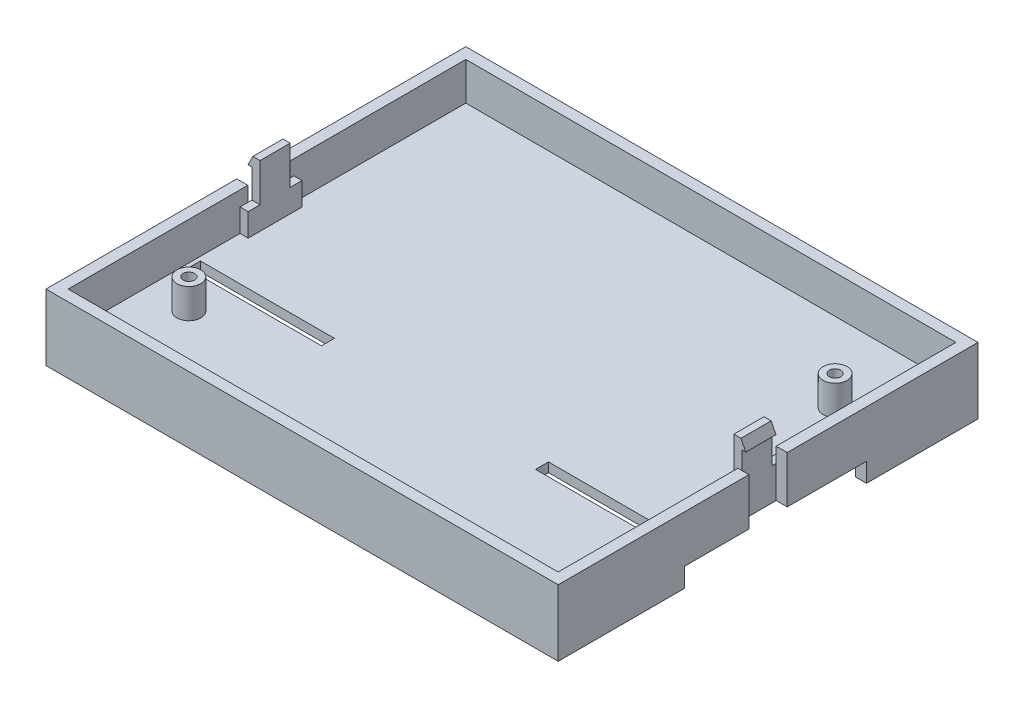
from build123d import *

# Parameters (mm, degrees)
CROQUIS1_W                          = 103.98
CROQUIS1_H                          = 2.475
SALIENTE_EXTRUIR1_DEPTH             = 2
SALIENTE_EXTRUIR2_DEPTH             = 6.3
CROQUIS3_W                          = 103.98
CROQUIS3_H                          = 8.775
SALIENTE_EXTRUIR3_DEPTH             = 12.75
CORTAR_EXTRUIR1_DEPTH               = 0.8
CORTAR_EXTRUIR2_DEPTH               = 0.8
CROQUIS6_W                          = 8.775
CROQUIS6_H                          = 12.8
CORTAR_EXTRUIR3_DEPTH               = 98.98
CROQUIS7_W                          = 1.7
CROQUIS7_H                          = 2.475
CORTAR_EXTRUIR4_DEPTH               = 2
CROQUIS8_W                          = 1.7
CROQUIS8_H                          = 2.475
CORTAR_EXTRUIR5_DEPTH               = 6
CROQUIS9_W                          = 1.7
CROQUIS9_H                          = 2.475
CORTAR_EXTRUIR6_DEPTH               = 6
SALIENTE_EXTRUIR4_DEPTH             = 2.475
CROQUIS11_W                         = 102.38
CROQUIS11_H                         = 1.95
SALIENTE_EXTRUIR5_DEPTH             = 38.225
CROQUIS12_W                         = 102.38
CROQUIS12_H                         = 2.31
SALIENTE_EXTRUIR6_DEPTH             = 7.9
CROQUIS13_W                         = 102.38
CROQUIS13_H                         = 1.95
SALIENTE_EXTRUIR7_DEPTH             = 38.225
CROQUIS14_W                         = 39.85
CROQUIS14_H                         = 9.85
SALIENTE_EXTRUIR8_DEPTH             = 2.31
CROQUIS15_W                         = 39.85
CROQUIS15_H                         = 9.85
SALIENTE_EXTRUIR9_DEPTH             = 2.31
CROQUIS16_W                         = 28
CROQUIS16_H                         = 2.7
CORTAR_EXTRUIR7_DEPTH               = 2.95
CROQUIS17_W                         = 28
CROQUIS17_H                         = 2.7
CORTAR_EXTRUIR8_DEPTH               = 2.95
CROQUIS18_W                         = 107
CROQUIS18_H                         = 26.41
SALIENTE_EXTRUIR10_DEPTH            = 4
CROQUIS19_W                         = 102.38
CROQUIS19_H                         = 2.31
SALIENTE_EXTRUIR11_DEPTH            = 7.9
CROQUIS20_W                         = 39.85
CROQUIS20_H                         = 9.85
SALIENTE_EXTRUIR12_DEPTH            = 2.31
CROQUIS21_W                         = 39.85
CROQUIS21_H                         = 9.85
SALIENTE_EXTRUIR13_DEPTH            = 2.31
SALIENTE_EXTRUIR14_DEPTH            = 4
SALIENTE_EXTRUIR15_DEPTH            = 4
CROQUIS24_W                         = 47
CROQUIS24_H                         = 4
CORTAR_EXTRUIR9_DEPTH               = 24.1
CORTAR_EXTRUIR10_REACH              = 106.69
CROQUIS25_W                         = 22.3
CROQUIS25_H                         = 4
CORTAR_EXTRUIR11_REACH              = 106.69
CROQUIS26_W                         = 4
CROQUIS26_H                         = 22.3
SALIENTE_EXTRUIR16_DEPTH            = 25.9
SALIENTE_EXTRUIR17_DEPTH            = 25.9
CROQUIS29_W                         = 2.5
CROQUIS29_H                         = 6.2
CROQUIS30_W                         = 2.5
CROQUIS30_H                         = 6.2
DI_METRO_DE_TALADRO_2_4_2_4_1_D     = 2.4
DI_METRO_DE_TALADRO_2_4_2_4_1_DEPTH = 6.2


with BuildPart() as part:
    # Croquis1 → Saliente-Extruir1 (new body)
    with BuildSketch(Plane(origin=(0, 18.75, 0), x_dir=(1, 0, 0), z_dir=(0, 1, 0))):
        with Locations((0, 4.3875)):
            Rectangle(CROQUIS1_W, CROQUIS1_H)
    extrude(amount=-SALIENTE_EXTRUIR1_DEPTH)

    # Croquis2 → Saliente-Extruir2 (add)
    with BuildSketch(Plane.XY.offset(-3.15)):
        Polygon((-51.99, 16.75), (-50.99, 18.75), (50.99, 18.75), (51.99, 16.75), align=None)
    extrude(amount=SALIENTE_EXTRUIR2_DEPTH)

    # Croquis3 → Saliente-Extruir3 (add)
    with BuildSketch(Plane.XZ.offset(-16.75)):
        with Locations((0, -1.2375)):
            Rectangle(CROQUIS3_W, CROQUIS3_H)
    extrude(amount=SALIENTE_EXTRUIR3_DEPTH)

    # Croquis4 → Cortar-Extruir1 (cut)
    with BuildSketch(Plane(origin=(51.99, 0, 0), x_dir=(0, 0, -1), z_dir=(1, 0, 0))):
        Polygon((5.625, 4), (5.625, 18.75), (3.15, 18.75), (3.15, 18.35), (3.15, 16.75), (-3.15, 16.75), (-3.15, 4), align=None)
    extrude(amount=-CORTAR_EXTRUIR1_DEPTH, mode=Mode.SUBTRACT)

    # Croquis5 → Cortar-Extruir2 (cut)
    with BuildSketch(Plane.ZY.offset(51.99)):
        Polygon((-5.625, 4), (3.15, 4), (3.15, 16.75), (-3.15, 16.75), (-3.15, 18.35), (-3.15, 18.75), (-5.625, 18.75), align=None)
    extrude(amount=-CORTAR_EXTRUIR2_DEPTH, mode=Mode.SUBTRACT)

    # Croquis6 → Cortar-Extruir3 (cut)
    with BuildSketch(Plane(origin=(49.49, 0, 0), x_dir=(0, 0, -1), z_dir=(1, 0, 0))):
        with Locations((1.2375, 12.35)):
            Rectangle(CROQUIS6_W, CROQUIS6_H)
    extrude(amount=-CORTAR_EXTRUIR3_DEPTH, mode=Mode.SUBTRACT)

    # Croquis7 → Cortar-Extruir4 (cut)
    with BuildSketch(Plane(origin=(0, 18.75, 0), x_dir=(-1, 0, 0), z_dir=(0, 1, 0))):
        with Locations((50.34, -4.3875)):
            Rectangle(CROQUIS7_W, CROQUIS7_H)
        with Locations((-50.34, -4.3875)):
            Rectangle(CROQUIS7_W, CROQUIS7_H)
    extrude(amount=-CORTAR_EXTRUIR4_DEPTH, mode=Mode.SUBTRACT)

    # Croquis8 → Cortar-Extruir5 (cut)
    with BuildSketch(Plane(origin=(0, 16.75, 0), x_dir=(-1, 0, 0), z_dir=(0, 1, 0))):
        with Locations((-50.34, -4.3875)):
            Rectangle(CROQUIS8_W, CROQUIS8_H)
    extrude(amount=-CORTAR_EXTRUIR5_DEPTH, mode=Mode.SUBTRACT)

    # Croquis9 → Cortar-Extruir6 (cut)
    with BuildSketch(Plane(origin=(0, 16.75, 0), x_dir=(-1, 0, 0), z_dir=(0, 1, 0))):
        with Locations((50.34, -4.3875)):
            Rectangle(CROQUIS9_W, CROQUIS9_H)
    extrude(amount=-CORTAR_EXTRUIR6_DEPTH, mode=Mode.SUBTRACT)

    # Croquis10 → Saliente-Extruir4 (add)
    with BuildSketch(Plane.XY.offset(3.15)):
        Polygon((49.49, 5.95), (49.49, 10.75), (51.19, 10.75), (51.19, 4), (-51.19, 4), (-51.19, 10.75), (-49.49, 10.75), (-49.49, 5.95), align=None)
    extrude(amount=SALIENTE_EXTRUIR4_DEPTH)

    # Croquis11 → Saliente-Extruir5 (add)
    with BuildSketch(Plane.XY.offset(5.625)):
        with Locations((0, 4.975)):
            Rectangle(CROQUIS11_W, CROQUIS11_H)
    extrude(amount=SALIENTE_EXTRUIR5_DEPTH)

    # Croquis12 → Saliente-Extruir6 (add)
    with BuildSketch(Plane(origin=(0, 5.95, 0), x_dir=(-1, 0, 0), z_dir=(0, 1, 0))):
        with Locations((0, 42.695)):
            Rectangle(CROQUIS12_W, CROQUIS12_H)
    extrude(amount=SALIENTE_EXTRUIR6_DEPTH)

    # Croquis13 → Saliente-Extruir7 (add)
    with BuildSketch(Plane(origin=(0, 0, -5.625), x_dir=(-1, 0, 0), z_dir=(0, 0, -1))):
        with Locations((0, 4.975)):
            Rectangle(CROQUIS13_W, CROQUIS13_H)
    extrude(amount=SALIENTE_EXTRUIR7_DEPTH)

    # Croquis14 → Saliente-Extruir8 (add)
    with BuildSketch(Plane.ZY.offset(51.19)):
        with Locations((23.925, 8.925)):
            Rectangle(CROQUIS14_W, CROQUIS14_H)
    extrude(amount=SALIENTE_EXTRUIR8_DEPTH)

    # Croquis15 → Saliente-Extruir9 (add)
    with BuildSketch(Plane(origin=(51.19, 0, 0), x_dir=(0, 0, -1), z_dir=(1, 0, 0))):
        with Locations((-23.925, 8.925)):
            Rectangle(CROQUIS15_W, CROQUIS15_H)
    extrude(amount=SALIENTE_EXTRUIR9_DEPTH)

    # Croquis16 → Cortar-Extruir7 (cut, through all)
    with BuildSketch(Plane(origin=(0, 5.95, 0), x_dir=(-1, 0, 0), z_dir=(0, 1, 0))):
        with Locations((36.36, 16.09)):
            Rectangle(CROQUIS16_W, CROQUIS16_H)
    extrude(amount=-CORTAR_EXTRUIR7_DEPTH, mode=Mode.SUBTRACT)

    # Croquis17 → Cortar-Extruir8 (cut, through all)
    with BuildSketch(Plane(origin=(0, 5.95, 0), x_dir=(-1, 0, 0), z_dir=(0, 1, 0))):
        with Locations((-36.36, 16.09)):
            Rectangle(CROQUIS17_W, CROQUIS17_H)
    extrude(amount=-CORTAR_EXTRUIR8_DEPTH, mode=Mode.SUBTRACT)

    # Croquis18 → Saliente-Extruir10 (add)
    with BuildSketch(Plane.XZ.offset(-4)):
        with Locations((0, 30.645)):
            Rectangle(CROQUIS18_W, CROQUIS18_H)
    extrude(amount=SALIENTE_EXTRUIR10_DEPTH)

    # Croquis19 → Saliente-Extruir11 (add)
    with BuildSketch(Plane(origin=(0, 5.95, 0), x_dir=(-1, 0, 0), z_dir=(0, 1, 0))):
        with Locations((0, -42.695)):
            Rectangle(CROQUIS19_W, CROQUIS19_H)
    extrude(amount=SALIENTE_EXTRUIR11_DEPTH)

    # Croquis20 → Saliente-Extruir12 (add)
    with BuildSketch(Plane(origin=(51.19, 0, 0), x_dir=(0, 0, -1), z_dir=(1, 0, 0))):
        with Locations((23.925, 8.925)):
            Rectangle(CROQUIS20_W, CROQUIS20_H)
    extrude(amount=SALIENTE_EXTRUIR12_DEPTH)

    # Croquis21 → Saliente-Extruir13 (add)
    with BuildSketch(Plane.ZY.offset(51.19)):
        with Locations((-23.925, 8.925)):
            Rectangle(CROQUIS21_W, CROQUIS21_H)
    extrude(amount=SALIENTE_EXTRUIR13_DEPTH)

    # Croquis22 → Saliente-Extruir14 (add)
    with BuildSketch(Plane.XZ.offset(-4)):
        Polygon((-53.5, -43.85), (-53.5, -20.56), (-51.19, -20.56), (-51.19, -41.54), (-10.19, -41.54), (-10.19, -22.86), (-40.69, -22.86), (-42.704360061, -23.54), (-43.44, -21.360818071), (-41.067741267, -20.56), (-6.19, -20.56), (-6.19, -43.85), align=None)
    extrude(amount=SALIENTE_EXTRUIR14_DEPTH)

    # Croquis23 → Saliente-Extruir15 (add)
    with BuildSketch(Plane.XZ.offset(-4)):
        Polygon((53.5, -43.85), (6.19, -43.85), (6.19, -20.56), (41.067741267, -20.56), (43.44, -21.360818071), (42.704360061, -23.54), (40.69, -22.86), (10.19, -22.86), (10.19, -41.54), (51.19, -41.54), (51.19, -20.56), (53.5, -20.56), align=None)
    extrude(amount=SALIENTE_EXTRUIR15_DEPTH)

    # Croquis24 → Cortar-Extruir9 (cut)
    with BuildSketch(Plane(origin=(0, 0, 17.44), x_dir=(-1, 0, 0), z_dir=(0, 0, -1))):
        with Locations((0, 2)):
            Rectangle(CROQUIS24_W, CROQUIS24_H)
    extrude(amount=-CORTAR_EXTRUIR9_DEPTH, mode=Mode.SUBTRACT)

    # Croquis25 → Cortar-Extruir10 (cut, up to next)
    with BuildSketch(Plane(origin=(51.19, 0, 0), x_dir=(0, 0, -1), z_dir=(1, 0, 0)), mode=Mode.PRIVATE) as cortar_extruir10_sk1:
        with Locations((-30.39, 2)):
            Rectangle(CROQUIS25_W, CROQUIS25_H)
    cortar_extruir10_tool1 = extrude(cortar_extruir10_sk1.sketch, amount=-CORTAR_EXTRUIR10_REACH, mode=Mode.PRIVATE) & part.part
    add(cortar_extruir10_tool1.solids().sort_by_distance((51.19, 2, 30.39))[0], mode=Mode.SUBTRACT)

    # Croquis26 → Cortar-Extruir11 (cut, up to next)
    with BuildSketch(Plane(origin=(-51.19, 0, 0), x_dir=(0, -1, 0), z_dir=(-1, 0, 0)), mode=Mode.PRIVATE) as cortar_extruir11_sk1:
        with Locations((-2, 30.39)):
            Rectangle(CROQUIS26_W, CROQUIS26_H)
    cortar_extruir11_tool1 = extrude(cortar_extruir11_sk1.sketch, amount=-CORTAR_EXTRUIR11_REACH, mode=Mode.PRIVATE) & part.part
    add(cortar_extruir11_tool1.solids().sort_by_distance((-51.19, 2, 30.39))[0], mode=Mode.SUBTRACT)

    # Croquis27 → Saliente-Extruir16 (add)
    with BuildSketch(Plane(origin=(23.5, 0, 0), x_dir=(0, -1, 0), z_dir=(-1, 0, 0))):
        Polygon((-2.45, 16.74), (-0.45, 14.74), (0, 14.74), (0, 17.44), (-2.45, 17.44), align=None)
    extrude(amount=-SALIENTE_EXTRUIR16_DEPTH)

    # Croquis28 → Saliente-Extruir17 (add)
    with BuildSketch(Plane(origin=(-23.5, 0, 0), x_dir=(0, 0, -1), z_dir=(1, 0, 0))):
        Polygon((-14.74, 0.45), (-16.74, 2.45), (-17.44, 2.45), (-17.44, 0), (-14.74, 0), align=None)
    extrude(amount=-SALIENTE_EXTRUIR17_DEPTH)

    # Croquis29 → Revolución1 (revolve)
    with BuildSketch(Plane.XY.offset(25)):
        with Locations((-41.25, 9.05)):
            Rectangle(CROQUIS29_W, CROQUIS29_H)
    revolve(axis=Axis((-42.5, 12.15, 25), (0, -1, 0)))

    # Croquis30 → Revolución2 (revolve)
    with BuildSketch(Plane.XY.offset(-25)):
        with Locations((43.75, 9.05)):
            Rectangle(CROQUIS30_W, CROQUIS30_H)
    revolve(axis=Axis((42.5, 12.15, -25), (0, -1, 0)))

    # Diámetro de taladro Ø2.4 (2.4)1
    with Locations(Plane(origin=(0, 12.15, 0), x_dir=(1, 0, 0), z_dir=(0, 1, 0))):
        with Locations((42.5, 25), (-42.5, -25)):
            Hole(DI_METRO_DE_TALADRO_2_4_2_4_1_D / 2, depth=DI_METRO_DE_TALADRO_2_4_2_4_1_DEPTH)


solid = part.part
